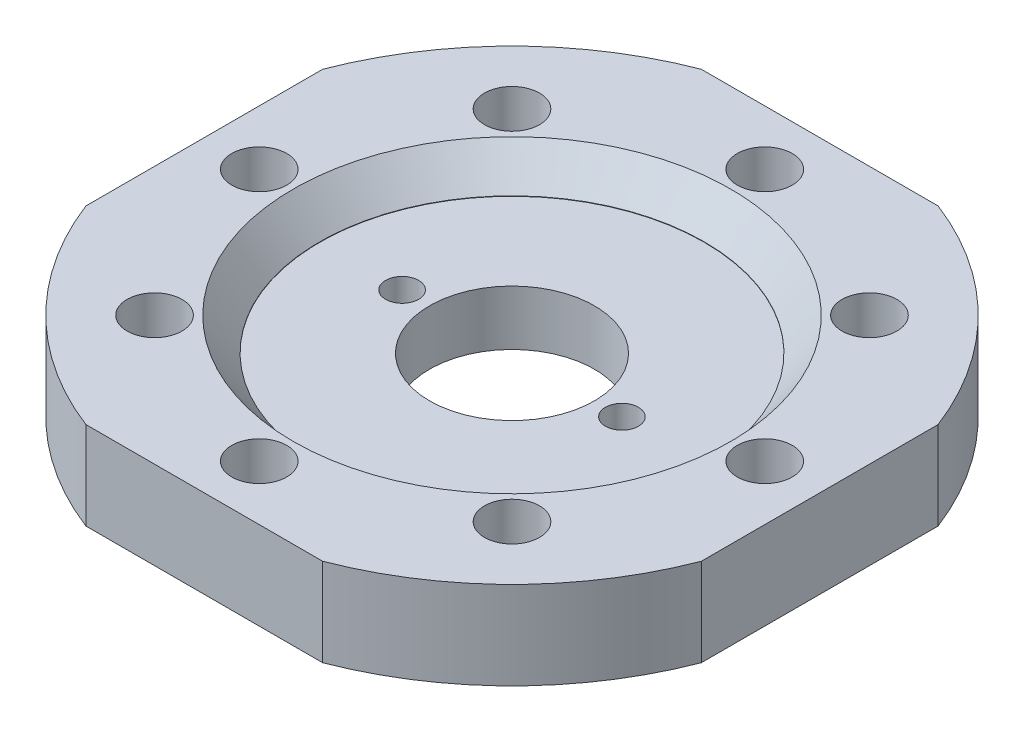
from build123d import *

# Parameters (mm, degrees)
SKETCH1_R                                = 150
BOSS_EXTRUDE1_DEPTH                      = 40
CBORE_FOR_M64_HEX_HEAD_BOLT1_D           = 75
CBORE_FOR_M64_HEX_HEAD_BOLT1_CBORE_D     = 175
CBORE_FOR_M64_HEX_HEAD_BOLT1_CBORE_DEPTH = 15
F_25_0_25_DIAMETER_HOLE1_D               = 25
CIRPATTERN2_COUNT                        = 8
CHAMFER1_SIZE                            = 12
CHAMFER1_SIZE2                           = 14.818765878
F_15_0_15_DIAMETER_HOLE1_D               = 15
F_15_0_15_DIAMETER_HOLE1_DEPTH           = 15
F_15_0_15_DIAMETER_HOLE1_TIP             = 4.506454643


with BuildPart() as part:
    # Sketch1 → Boss-Extrude1 (new body)
    with BuildSketch(Plane(origin=(0, 0, 0), x_dir=(1, 0, 0), z_dir=(0, 1, 0))):
        with Locations(Location((0, 0, 0), (0, 0, 270))):
            Circle(SKETCH1_R)
    extrude(amount=BOSS_EXTRUDE1_DEPTH)

    # CBORE for M64 Hex Head Bolt1 (through all)
    with Locations(Plane(origin=(0, 40, 0), x_dir=(1, 0, 0), z_dir=(0, 1, 0))):
        with Locations((0, 0)):
            CounterBoreHole(CBORE_FOR_M64_HEX_HEAD_BOLT1_D / 2, CBORE_FOR_M64_HEX_HEAD_BOLT1_CBORE_D / 2, CBORE_FOR_M64_HEX_HEAD_BOLT1_CBORE_DEPTH)

    # Ø25.0 (25) Diameter Hole1 (through all)
    with Locations(Plane(origin=(0, 40, 0), x_dir=(1, 0, 0), z_dir=(0, 1, 0))):
        with Locations((115, 0)):
            f_25_0_25_diameter_hole1 = Hole(F_25_0_25_DIAMETER_HOLE1_D / 2)

    # CirPattern2: Ø25.0 (25) Diameter Hole1 ×8 about axis
    cirpattern2_axis = Axis((0, 0, 0), (0, 1, 0))
    for i in range(1, CIRPATTERN2_COUNT):
        add(f_25_0_25_diameter_hole1.rotate(cirpattern2_axis, i * 360 / CIRPATTERN2_COUNT), mode=Mode.SUBTRACT)

    # Chamfer1
    chamfer1_edges = [part.edges().sort_by_distance(p)[0] for p in [
        (-87.5, 40, 0),
    ]]
    chamfer1_side = [part.faces().sort_by_distance(p)[0] for p in [
        (0, 40, -145.757359313),
    ]]
    chamfer(chamfer1_edges, length=CHAMFER1_SIZE, length2=CHAMFER1_SIZE2, reference=chamfer1_side[0])

    # SurfaceCut1
    split(bisect_by=Plane(origin=(-140, 0, 0), x_dir=(0, 0, -1), z_dir=(1, 0, 0)), keep=Keep.TOP)

    # SurfaceCut2
    split(bisect_by=Plane.XY.offset(140), keep=Keep.BOTTOM)

    # SurfaceCut3
    split(bisect_by=Plane(origin=(140, 0, 0), x_dir=(0, 0, -1), z_dir=(1, 0, 0)), keep=Keep.BOTTOM)

    # SurfaceCut4
    split(bisect_by=Plane.XY.offset(-140), keep=Keep.TOP)

    # Ø15.0 (15) Diameter Hole1
    with Locations(Plane(origin=(0, 25, 0), x_dir=(1, 0, 0), z_dir=(0, 1, 0))):
        with Locations((-50, 0), (50, 0)):
            Hole(F_15_0_15_DIAMETER_HOLE1_D / 2, depth=F_15_0_15_DIAMETER_HOLE1_DEPTH)
            with Locations((0, 0, -(F_15_0_15_DIAMETER_HOLE1_DEPTH + F_15_0_15_DIAMETER_HOLE1_TIP / 2))):  # 118° drill point
                Cone(0, F_15_0_15_DIAMETER_HOLE1_D / 2, F_15_0_15_DIAMETER_HOLE1_TIP, mode=Mode.SUBTRACT)


solid = part.part
